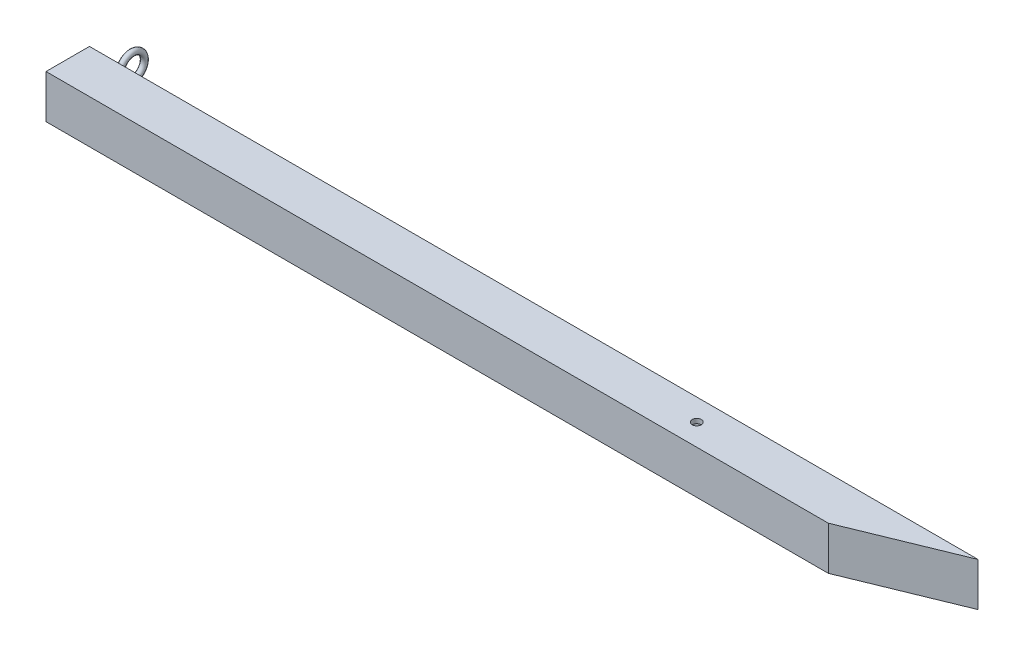
from build123d import *

# Parameters (mm, degrees)
SKETCH2_W           = 38
SKETCH2_H           = 38
SKETCH3_W           = 30
SKETCH3_H           = 30
SKETCH4_R           = 4
CUT_EXTRUDE1_DEPTH  = 764.819309892
SWEEP2_PROFILE_R    = 2.5
CUT_EXTRUDE2_DEPTH  = 766.523252428
BOSS_EXTRUDE1_DEPTH = 38
SKETCH22_W          = 30
SKETCH22_H          = 30
CUT_EXTRUDE3_DEPTH  = 837.549484437
CUT_EXTRUDE4_DEPTH  = 766.523252428
CUT_EXTRUDE5_DEPTH  = 766.523252428
BOSS_EXTRUDE2_REACH = 767.523


with BuildPart() as part:
    # Sweep1: sweep along a path in Sketch1
    with BuildLine(Plane(origin=(0, 0, 0), x_dir=(1, 0, 0), z_dir=(0, 1, 0))) as sweep1_path:
        Line((0, 0), (-762.63683242, 0))
    # Sketch2 → Sweep1 (sweep)
    with BuildSketch(Plane(origin=(0, 0, 0), x_dir=(0, 0, -1), z_dir=(1, 0, 0))):
        Rectangle(SKETCH2_W, SKETCH2_H)
    sweep(path=sweep1_path.line)

    # Cut-Sweep1: sweep along a path in Sketch1_2
    with BuildLine(Plane(origin=(0, 0, 0), x_dir=(1, 0, 0), z_dir=(0, 1, 0))) as cut_sweep1_path:
        Line((0, 0), (-762.63683242, 0))
    # Sketch3 → Cut-Sweep1 (sweep, cut)
    with BuildSketch(Plane(origin=(0, 0, 0), x_dir=(0, 0, -1), z_dir=(1, 0, 0))):
        Rectangle(SKETCH3_W, SKETCH3_H)
    sweep(path=cut_sweep1_path.line, mode=Mode.SUBTRACT)

    # Sketch4 → Cut-Extrude1 (cut, through all)
    with BuildSketch(Plane(origin=(0, 19, 0), x_dir=(1, 0, 0), z_dir=(0, 1, 0))):
        with Locations((-212.63683242, 0)):
            Circle(SKETCH4_R)
    extrude(amount=-CUT_EXTRUDE1_DEPTH, mode=Mode.SUBTRACT)

    # Sweep2: sweep along a path in Sketch5
    with BuildLine(Plane.ZY.offset(747.63683242)) as sweep2_path:
        Line((-19, 0), (-26.570946825, 0))
        ThreePointArc((-26.570946825, 0), (-29.503401087, 0.950220747), (-31.321263798, 3.4397152))
        ThreePointArc((-31.321263798, 3.4397152), (-51.969366005, 0.135523131), (-31.321263798, -3.168668939))
    # Sweep2 profile (on start of the path) → Sweep2 (sweep)
    with BuildSketch(Plane(origin=(-747.63683242, 0, -19), x_dir=(0, -1, 0), z_dir=(0, 0, -1))):
        Circle(SWEEP2_PROFILE_R)
    sweep(path=sweep2_path.line)

    # Sketch16 → Cut-Extrude2 (cut, through all)
    with BuildSketch(Plane(origin=(0, 19, 0), x_dir=(1, 0, 0), z_dir=(0, 1, 0))):
        Polygon((0, -19), (0, 19), (-71.907398101, -19), align=None)
    extrude(amount=-CUT_EXTRUDE2_DEPTH, mode=Mode.SUBTRACT)

    # Sketch17 → Boss-Extrude1 (add)
    with BuildSketch(Plane(origin=(0, 19, 0), x_dir=(1, 0, 0), z_dir=(0, 1, 0))):
        Polygon((-71.907398101, -19), (0, -19), (71.921211139, 19), (0, 19), align=None)
    extrude(amount=-BOSS_EXTRUDE1_DEPTH)

    # Sketch22 → Cut-Extrude3 (cut, through all)
    with BuildSketch(Plane.ZY.offset(762.63683242)):
        Rectangle(SKETCH22_W, SKETCH22_H)
    extrude(amount=-CUT_EXTRUDE3_DEPTH, mode=Mode.SUBTRACT)

    # Sketch23 → Cut-Extrude4 (cut, through all)
    with BuildSketch(Plane(origin=(0, 19, 0), x_dir=(1, 0, 0), z_dir=(0, 1, 0))):
        Polygon((14.258492684, 0), (-32.20683242, -19), (0, -19), (71.921211139, 19), (60.723817789, 19), align=None)
    extrude(amount=-CUT_EXTRUDE4_DEPTH, mode=Mode.SUBTRACT)

    # Sketch24 → Cut-Extrude5 (cut, through all)
    with BuildSketch(Plane(origin=(0, 19, 0), x_dir=(1, 0, 0), z_dir=(0, 1, 0))):
        Polygon((-78.672157524, -19), (14.258492684, 19), (60.723817789, 19), (-32.20683242, -19), align=None)
    extrude(amount=-CUT_EXTRUDE5_DEPTH, mode=Mode.SUBTRACT)

    # Sketch25 → Boss-Extrude2 (add, up to next)
    with BuildSketch(Plane(origin=(0, 19, 0), x_dir=(1, 0, 0), z_dir=(0, 1, 0)), mode=Mode.PRIVATE) as boss_extrude2_sk1:
        Polygon((3.690100071, 19), (-89.240550137, -19), (-78.672157524, -19), (14.258492684, 19), align=None)
    boss_extrude2_tool1 = extrude(boss_extrude2_sk1.sketch, amount=-BOSS_EXTRUDE2_REACH, mode=Mode.PRIVATE) - part.part
    add(boss_extrude2_tool1.solids().sort_by_distance((-37.491029, 19, 0))[0])


solid = part.part
